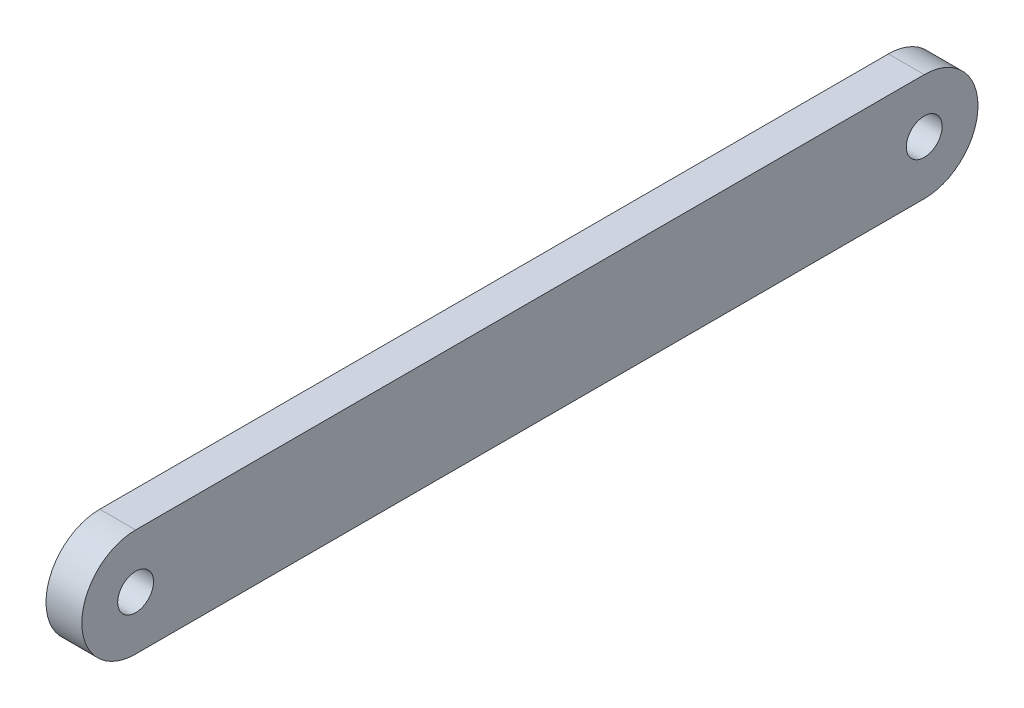
from build123d import *

# Parameters (mm, degrees)
BOSS_EXTRUDE1_DEPTH = 10
CUT_EXTRUDE1_REACH  = 12
SKETCH3_R           = 5
CUT_EXTRUDE3_REACH  = 12
SKETCH2_R           = 5


with BuildPart() as part:
    # Sketch1 → Boss-Extrude1 (new body)
    with BuildSketch(Plane(origin=(0, 0, 0), x_dir=(0, 0, -1), z_dir=(1, 0, 0))):
        with BuildLine():
            Line((-110, 15), (110, 15))
            ThreePointArc((110, 15), (125, 0), (110, -15))
            Line((110, -15), (-110, -15))
            ThreePointArc((-110, -15), (-125, 0), (-110, 15))
        make_face()
    extrude(amount=BOSS_EXTRUDE1_DEPTH)

    # Sketch3 → Cut-Extrude1 (cut, up to next)
    with BuildSketch(Plane.ZY, mode=Mode.PRIVATE) as cut_extrude1_sk1:
        with Locations((110, 0)):
            Circle(SKETCH3_R)
    cut_extrude1_tool1 = extrude(cut_extrude1_sk1.sketch, amount=-CUT_EXTRUDE1_REACH, mode=Mode.PRIVATE) & part.part
    add(cut_extrude1_tool1.solids().sort_by_distance((0, 0, 110))[0], mode=Mode.SUBTRACT)

    # Sketch2 → Cut-Extrude3 (cut, up to next)
    with BuildSketch(Plane.ZY, mode=Mode.PRIVATE) as cut_extrude3_sk1:
        with Locations((-110, 0)):
            Circle(SKETCH2_R)
    cut_extrude3_tool1 = extrude(cut_extrude3_sk1.sketch, amount=-CUT_EXTRUDE3_REACH, mode=Mode.PRIVATE) & part.part
    add(cut_extrude3_tool1.solids().sort_by_distance((0, 0, -110))[0], mode=Mode.SUBTRACT)


solid = part.part
